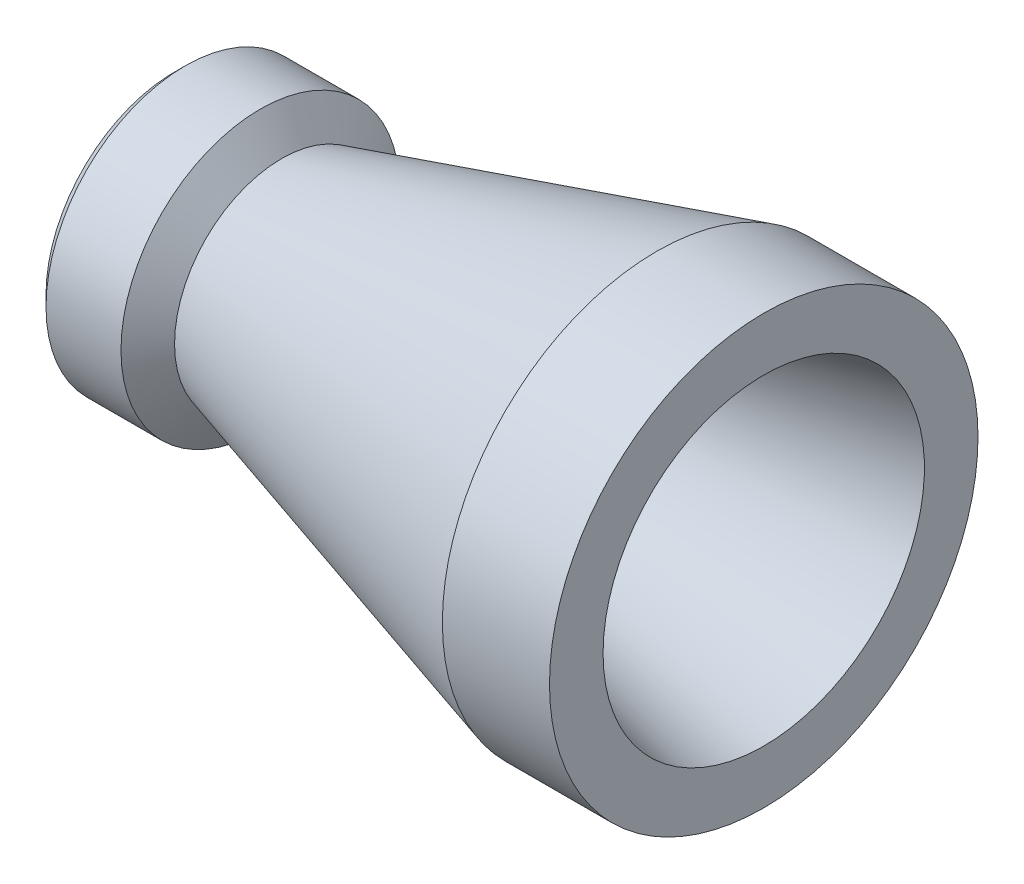
from build123d import *


with BuildPart() as part:
    # 草圖1 → 旋轉1 (revolve)
    with BuildSketch(Plane.XY):
        with BuildLine():
            Line((0, 5), (0, 12))
            Line((0, 12), (1, 13))
            Line((1, 13), (8, 13))
            Line((8, 13), (10, 10))
            Line((10, 10), (45, 20))
            Line((45, 20), (55, 20))
            Line((55, 20), (55, 15))
            Line((55, 15), (23.556757793, 7.853808589))
            ThreePointArc((23.556757793, 7.853808589), (22.436912604, 7.151243881), (22, 5.903542878))
            Line((22, 5.903542878), (22, 5))
            Line((22, 5), (0, 5))
        make_face()
    revolve(axis=Axis((0, 0, 0), (1, 0, 0)))


solid = part.part
